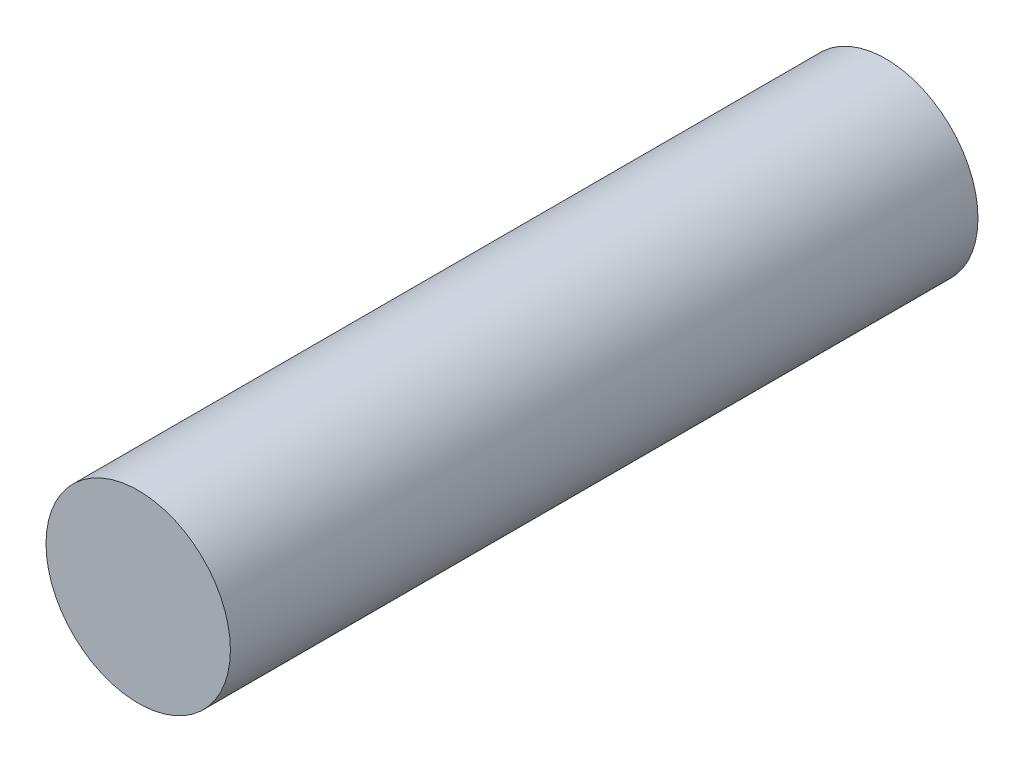
from build123d import *

# Parameters (mm, degrees)
SKETCH1_R          = 4.699
BASE_EXTRUDE_DEPTH = 38.1


with BuildPart() as part:
    # Sketch1 → Base-Extrude (new body)
    with BuildSketch(Plane.XY):
        Circle(SKETCH1_R)
    extrude(amount=BASE_EXTRUDE_DEPTH)


solid = part.part
